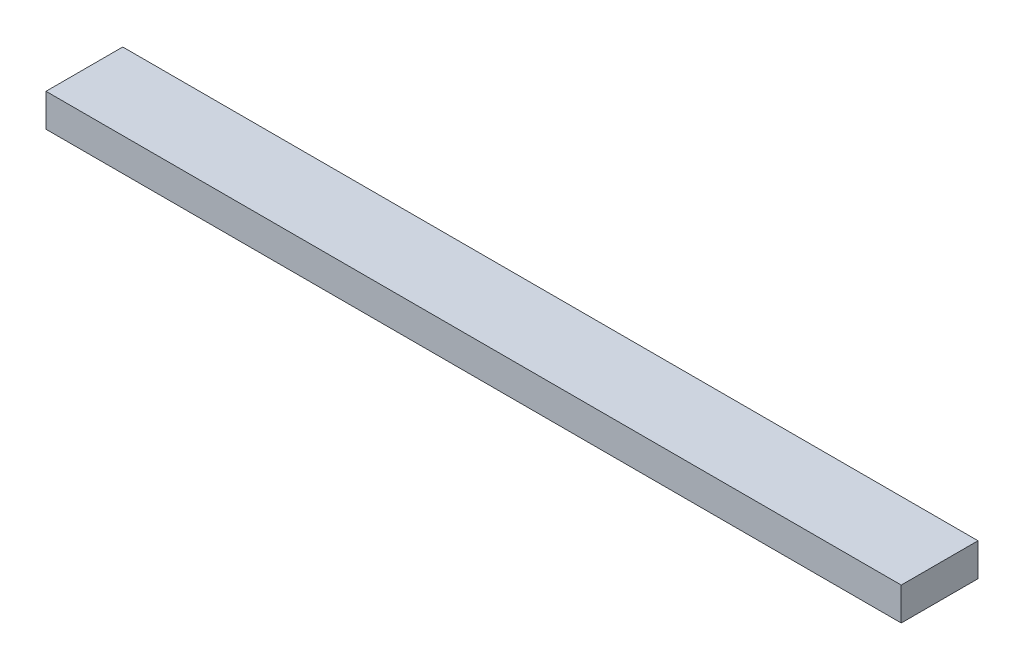
from build123d import *

# Parameters (mm, degrees)
SKETCH1_W           = 990.6
SKETCH1_H           = 88.9
BOSS_EXTRUDE1_DEPTH = 38.1


with BuildPart() as part:
    # Sketch1 → Boss-Extrude1 (new body)
    with BuildSketch(Plane(origin=(0, 0, 0), x_dir=(1, 0, 0), z_dir=(0, 1, 0))):
        with Locations((495.3, 44.45)):
            Rectangle(SKETCH1_W, SKETCH1_H)
    extrude(amount=BOSS_EXTRUDE1_DEPTH)


solid = part.part
